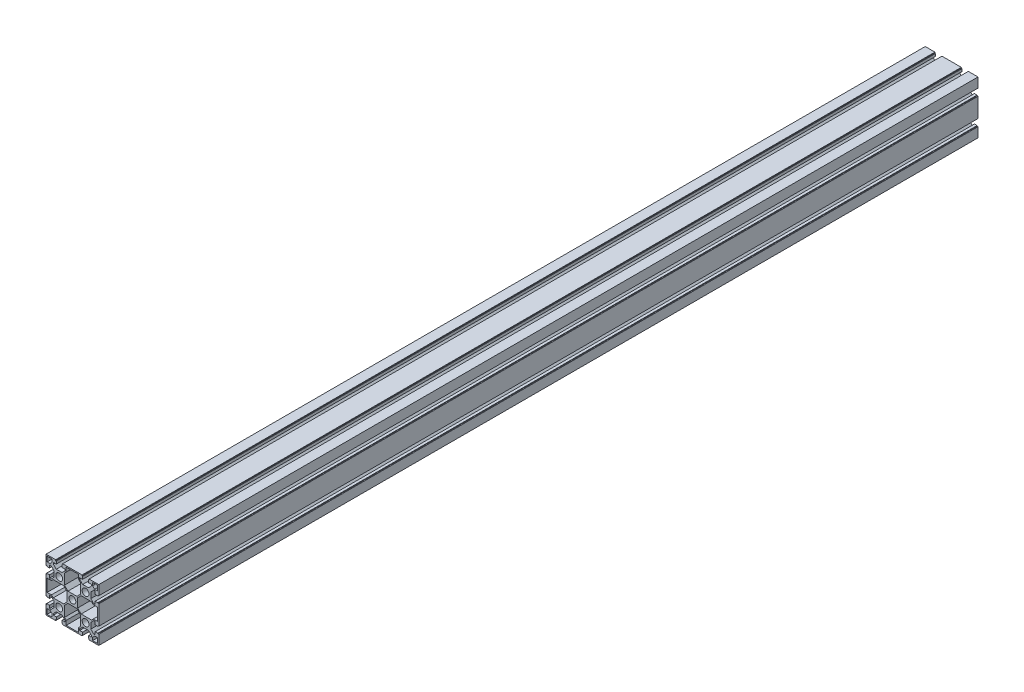
from build123d import *

# Parameters (mm, degrees)
CROQUIS1_R                   = 5.85
SALIENTE_EXTRUIR2_DEPTH      = 750
TALADRO_DE_MARGEN_PARA_M61_D = 6.4


with BuildPart() as part:
    # Croquis1 → Saliente-Extruir2 (new body, symmetric)
    with BuildSketch(Plane.XY):
        Polygon((-27.5, 31.5), (-32.5, 36.5), (-32.5, 39), (-27.5, 39), (-27.5, 43.5), (-28.5, 43.5), (-28.5, 45), (-45, 45), (-45, 28.5), (-43.5, 28.5), (-43.5, 27.5), (-39, 27.5), (-39, 32.5), (-36.5, 32.5), (-31.5, 27.5), (-31.5, 17.5), (-36.5, 12.5), (-39, 12.5), (-39, 17.5), (-43.5, 17.5), (-43.5, 16.5), (-45, 16.5), (-45, 0), (-45, -16.5), (-43.5, -16.5), (-43.5, -17.5), (-39, -17.5), (-39, -12.5), (-36.5, -12.5), (-31.5, -17.5), (-31.5, -27.5), (-36.5, -32.5), (-39, -32.5), (-39, -27.5), (-43.5, -27.5), (-43.5, -28.5), (-45, -28.5), (-45, -45), (-28.5, -45), (-28.5, -43.5), (-27.5, -43.5), (-27.5, -39), (-32.5, -39), (-32.5, -36.5), (-27.5, -31.5), (-17.5, -31.5), (-12.5, -36.5), (-12.5, -39), (-17.5, -39), (-17.5, -43.5), (-16.5, -43.5), (-16.5, -45), (0, -45), (16.5, -45), (16.5, -43.5), (17.5, -43.5), (17.5, -39), (12.5, -39), (12.5, -36.5), (17.5, -31.5), (27.5, -31.5), (32.5, -36.5), (32.5, -39), (27.5, -39), (27.5, -43.5), (28.5, -43.5), (28.5, -45), (45, -45), (45, -28.5), (43.5, -28.5), (43.5, -27.5), (39, -27.5), (39, -32.5), (36.5, -32.5), (31.5, -27.5), (31.5, -17.5), (36.5, -12.5), (39, -12.5), (39, -17.5), (43.5, -17.5), (43.5, -16.5), (45, -16.5), (45, 0), (45, 16.5), (43.5, 16.5), (43.5, 17.5), (39, 17.5), (39, 12.5), (36.5, 12.5), (31.5, 17.5), (31.5, 27.5), (36.5, 32.5), (39, 32.5), (39, 27.5), (43.5, 27.5), (43.5, 28.5), (45, 28.5), (45, 45), (28.5, 45), (28.5, 43.5), (27.5, 43.5), (27.5, 39), (32.5, 39), (32.5, 36.5), (27.5, 31.5), (17.5, 31.5), (12.5, 36.5), (12.5, 39), (17.5, 39), (17.5, 43.5), (16.5, 43.5), (16.5, 45), (0, 45), (-16.5, 45), (-16.5, 43.5), (-17.5, 43.5), (-17.5, 39), (-12.5, 39), (-12.5, 36.5), (-17.5, 31.5), align=None)
        Circle(CROQUIS1_R, mode=Mode.SUBTRACT)
        with Locations((-22.5, 22.5)):
            Circle(CROQUIS1_R, mode=Mode.SUBTRACT)
        with Locations((22.5, 22.5)):
            Circle(CROQUIS1_R, mode=Mode.SUBTRACT)
        with Locations((-22.5, -22.5)):
            Circle(CROQUIS1_R, mode=Mode.SUBTRACT)
        with Locations((22.5, -22.5)):
            Circle(CROQUIS1_R, mode=Mode.SUBTRACT)
        Polygon((-0.000752497, 43), (-10.5, 43), (-10.5, 35.671572875), (-13.5, 32.671572875), (-13.5, 14.914213562), (-7.585786438, 9), (-0.24688362, 9), (7.585786438, 9), (13.5, 14.914213562), (13.5, 32.671572875), (10.5, 35.671572875), (10.5, 43), align=None, mode=Mode.SUBTRACT)
        Polygon((-43, 43), (-43, 34.5), (-38, 34.5), (-34.5, 38), (-34.5, 43), align=None, mode=Mode.SUBTRACT)
        Polygon((38, 34.5), (34.5, 38), (34.5, 43), (43, 43), (43, 34.5), align=None, mode=Mode.SUBTRACT)
        Polygon((34.5, -38), (38, -34.5), (43, -34.5), (43, -43), (34.5, -43), align=None, mode=Mode.SUBTRACT)
        Polygon((-38, -34.5), (-34.5, -38), (-34.5, -43), (-43, -43), (-43, -34.5), align=None, mode=Mode.SUBTRACT)
        Polygon((32.671572875, -13.5), (14.914213562, -13.5), (9, -7.585786438), (9, 0.24688362), (9, 7.585786438), (14.914213562, 13.5), (32.671572875, 13.5), (35.671572875, 10.5), (43, 10.5), (43, 0.000752497), (43, -10.5), (35.671572875, -10.5), align=None, mode=Mode.SUBTRACT)
        Polygon((-13.5, -32.671572875), (-13.5, -14.914213562), (-7.585786438, -9), (0.24688362, -9), (7.585786438, -9), (13.5, -14.914213562), (13.5, -32.671572875), (10.5, -35.671572875), (10.5, -43), (0.000752497, -43), (-10.5, -43), (-10.5, -35.671572875), align=None, mode=Mode.SUBTRACT)
        Polygon((-32.671572875, 13.5), (-14.914213562, 13.5), (-9, 7.585786438), (-9, -0.24688362), (-9, -7.585786438), (-14.914213562, -13.5), (-32.671572875, -13.5), (-35.671572875, -10.5), (-43, -10.5), (-43, -0.000752497), (-43, 10.5), (-35.671572875, 10.5), align=None, mode=Mode.SUBTRACT)
    extrude(amount=SALIENTE_EXTRUIR2_DEPTH, both=True)

    # Taladro de margen para M61 (through all)
    with Locations(Plane(origin=(0, 45, 0), x_dir=(1, 0, 0), z_dir=(0, 1, 0))):
        with Locations((-22.5, 26), (-22.5, -26), (22.5, -26), (22.5, 26)):
            Hole(TALADRO_DE_MARGEN_PARA_M61_D / 2)


solid = part.part
